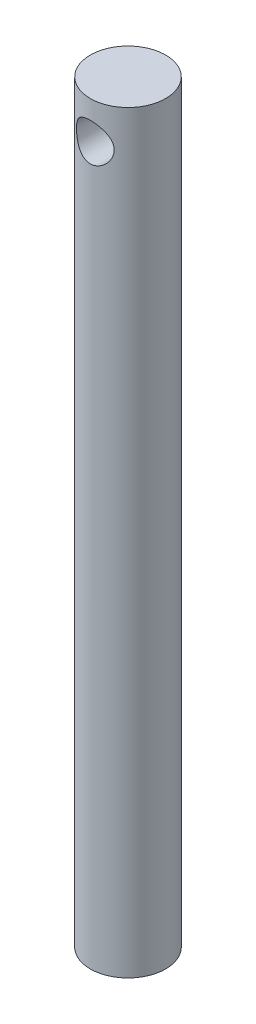
from build123d import *

# Parameters (mm, degrees)
SKETCH_1_R               = 5
EXTRUDE_1_DEPTH          = 100
SKETCH_2_R               = 2.5
CUT_EXTRUDE_1_DEPTH      = 10
CUT_EXTRUDE_1_DEPTH_BACK = 8


with BuildPart() as part:
    # Эскиз1 → Бобышка-Вытянуть1 (new body)
    with BuildSketch(Plane(origin=(0, 0, 0), x_dir=(1, 0, 0), z_dir=(0, 1, 0))):
        Circle(SKETCH_1_R)
    extrude(amount=EXTRUDE_1_DEPTH)

    # Эскиз2 → Вырез-Вытянуть1 (cut, two sides)
    with BuildSketch(Plane.XY) as cut_extrude_1_sk:
        with Locations((0, 95)):
            Circle(SKETCH_2_R)
    extrude(amount=CUT_EXTRUDE_1_DEPTH, mode=Mode.SUBTRACT)
    extrude(cut_extrude_1_sk.sketch, amount=-CUT_EXTRUDE_1_DEPTH_BACK, mode=Mode.SUBTRACT)


solid = part.part
